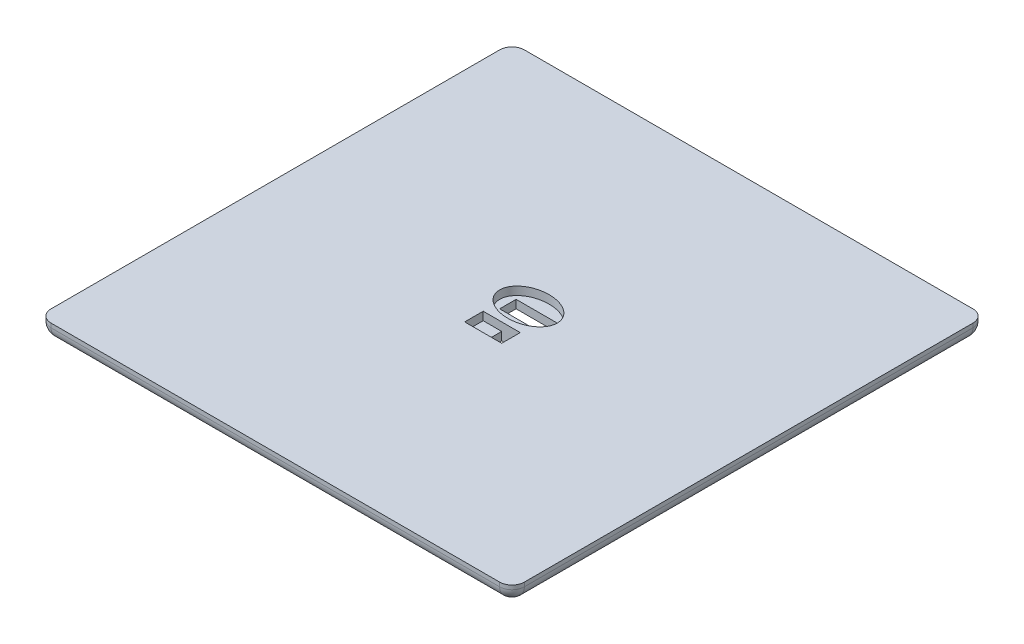
from build123d import *

# Parameters (mm, degrees)
BOSS_EXTRUDE4_DEPTH      = 47.5
BOSS_EXTRUDE4_DEPTH_BACK = 47.5
SKETCH7_W                = 95
SKETCH7_H                = 4
BOSS_EXTRUDE5_DEPTH      = 52.5
BOSS_EXTRUDE5_DEPTH_BACK = 52.5
SKETCH8_W                = 105
SKETCH8_H                = 4
BOSS_EXTRUDE6_DEPTH      = 57.5
BOSS_EXTRUDE6_DEPTH_BACK = 57.5
SKETCH9_W                = 115
SKETCH9_H                = 4
CUT_EXTRUDE1_DEPTH       = 8
CUT_EXTRUDE1_DEPTH_BACK  = 3.5
SKETCH10_W               = 85
SKETCH10_H               = 85
SKETCH12_RX              = 7
SKETCH12_RY              = 5
CUT_EXTRUDE2_DEPTH       = 2
CUT_EXTRUDE3_DEPTH       = 29
CUT_EXTRUDE3_DEPTH_BACK  = 83.197931847
SKETCH13_W               = 10
SKETCH13_H               = 4
FILLET4_R                = 3
SKETCH14_W               = 9
SKETCH14_H               = 4.5
CUT_EXTRUDE4_DEPTH       = 2
SKETCH16_W               = 4.5
SKETCH16_H               = 4.5
CUT_EXTRUDE5_DEPTH       = 10


with BuildPart() as part:
    # Sketch7 → Boss-Extrude4 (new, two sides: drawn at the far end of the back side and taken through both)
    with BuildSketch(Plane.XY.offset(-BOSS_EXTRUDE4_DEPTH_BACK)):
        with Locations((0, 2)):
            Rectangle(SKETCH7_W, SKETCH7_H)
    extrude(amount=BOSS_EXTRUDE4_DEPTH + BOSS_EXTRUDE4_DEPTH_BACK)

    # Sketch8 → Boss-Extrude5 (add, two sides: drawn at the far end of the back side and taken through both)
    with BuildSketch(Plane.XY.offset(-BOSS_EXTRUDE5_DEPTH_BACK)):
        with Locations((0, 6)):
            Rectangle(SKETCH8_W, SKETCH8_H)
    extrude(amount=BOSS_EXTRUDE5_DEPTH + BOSS_EXTRUDE5_DEPTH_BACK)

    # Sketch9 → Boss-Extrude6 (add, two sides: drawn at the far end of the back side and taken through both)
    with BuildSketch(Plane.XY.offset(-BOSS_EXTRUDE6_DEPTH_BACK)):
        with Locations((0, 10)):
            Rectangle(SKETCH9_W, SKETCH9_H)
    extrude(amount=BOSS_EXTRUDE6_DEPTH + BOSS_EXTRUDE6_DEPTH_BACK)

    # Sketch10 → Cut-Extrude1 (cut, two sides: drawn at the far end of the back side and taken through both)
    with BuildSketch(Plane(origin=(0, 0, 0), x_dir=(1, 0, 0), z_dir=(0, 1, 0)).offset(-CUT_EXTRUDE1_DEPTH_BACK)):
        Rectangle(SKETCH10_W, SKETCH10_H)
    extrude(amount=CUT_EXTRUDE1_DEPTH + CUT_EXTRUDE1_DEPTH_BACK, mode=Mode.SUBTRACT)

    # Sketch12 → Cut-Extrude2 (cut)
    with BuildSketch(Plane(origin=(0, 12, 0), x_dir=(1, 0, 0), z_dir=(0, 1, 0))):
        with Locations((0, 4)):
            Ellipse(SKETCH12_RX, SKETCH12_RY)
    extrude(amount=-CUT_EXTRUDE2_DEPTH, mode=Mode.SUBTRACT)

    # Sketch13 → Cut-Extrude3 (cut, two sides: drawn at the far end of the back side and taken through both)
    with BuildSketch(Plane(origin=(0, 0, 0), x_dir=(1, 0, 0), z_dir=(0, 1, 0)).offset(-CUT_EXTRUDE3_DEPTH_BACK)):
        with Locations((0, 4)):
            Rectangle(SKETCH13_W, SKETCH13_H)
    extrude(amount=CUT_EXTRUDE3_DEPTH + CUT_EXTRUDE3_DEPTH_BACK, mode=Mode.SUBTRACT)

    # Fillet4
    fillet4_edges = [part.edges().sort_by_distance(p)[0] for p in [
        (-47.5, 2, -47.5),
        (-52.5, 6, -52.5),
        (-57.5, 10, -57.5),
        (-47.5, 0, 0),
        (-52.5, 4, 0),
        (-57.5, 8, 0),
        (-57.5, 10, 57.5),
        (-52.5, 6, 52.5),
        (-47.5, 2, 47.5),
        (0, 8, -57.5),
        (0, 4, -52.5),
        (0, 0, -47.5),
        (47.5, 2, -47.5),
        (52.5, 6, -52.5),
        (57.5, 10, -57.5),
        (57.5, 10, 57.5),
        (0, 8, 57.5),
        (57.5, 8, 0),
        (52.5, 4, 0),
        (0, 4, 52.5),
        (52.5, 6, 52.5),
        (47.5, 2, 47.5),
        (47.5, 0, 0),
        (0, 0, 47.5),
    ]]
    fillet(fillet4_edges, radius=FILLET4_R)

    # Sketch14 → Cut-Extrude4 (cut)
    with BuildSketch(Plane(origin=(0, 12, 0), x_dir=(1, 0, 0), z_dir=(0, 1, 0))):
        with Locations((0, -4.75)):
            Rectangle(SKETCH14_W, SKETCH14_H)
    extrude(amount=-CUT_EXTRUDE4_DEPTH, mode=Mode.SUBTRACT)

    # Sketch16 → Cut-Extrude5 (cut)
    with BuildSketch(Plane(origin=(0, 12, 0), x_dir=(1, 0, 0), z_dir=(0, 1, 0))):
        with Locations((2.25, -4.75)):
            Rectangle(SKETCH16_W, SKETCH16_H)
    extrude(amount=-CUT_EXTRUDE5_DEPTH, mode=Mode.SUBTRACT)


solid = part.part
